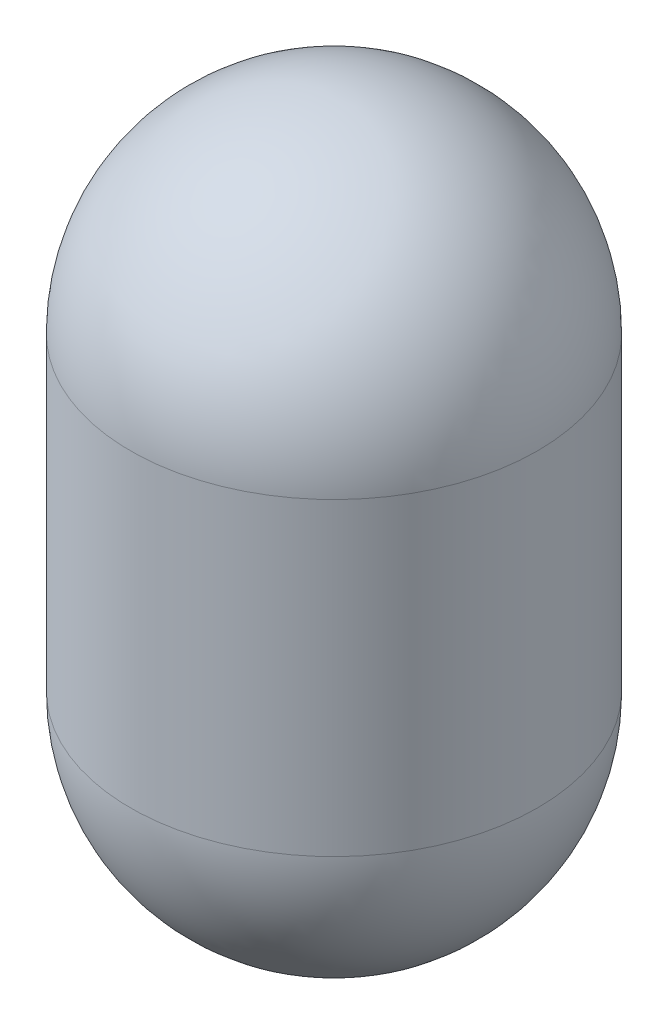
from build123d import *


with BuildPart() as part:
    # Sketch1 → Revolve1 (revolve)
    with BuildSketch(Plane.XY):
        with BuildLine():
            Line((0, 0), (0, 190))
            ThreePointArc((0, 190), (36.611652352, 278.388347648), (125, 315))
            Line((125, 315), (125, 305))
            ThreePointArc((125, 305), (43.682720164, 271.317279836), (10, 190))
            Line((10, 190), (10, 0))
            ThreePointArc((10, 0), (43.682720164, -81.317279836), (125, -115))
            Line((125, -115), (125, -125))
            ThreePointArc((125, -125), (36.611652352, -88.388347648), (0, 0))
        make_face()
    revolve(axis=Axis((125, 315, 0), (0, -1, 0)))


solid = part.part
